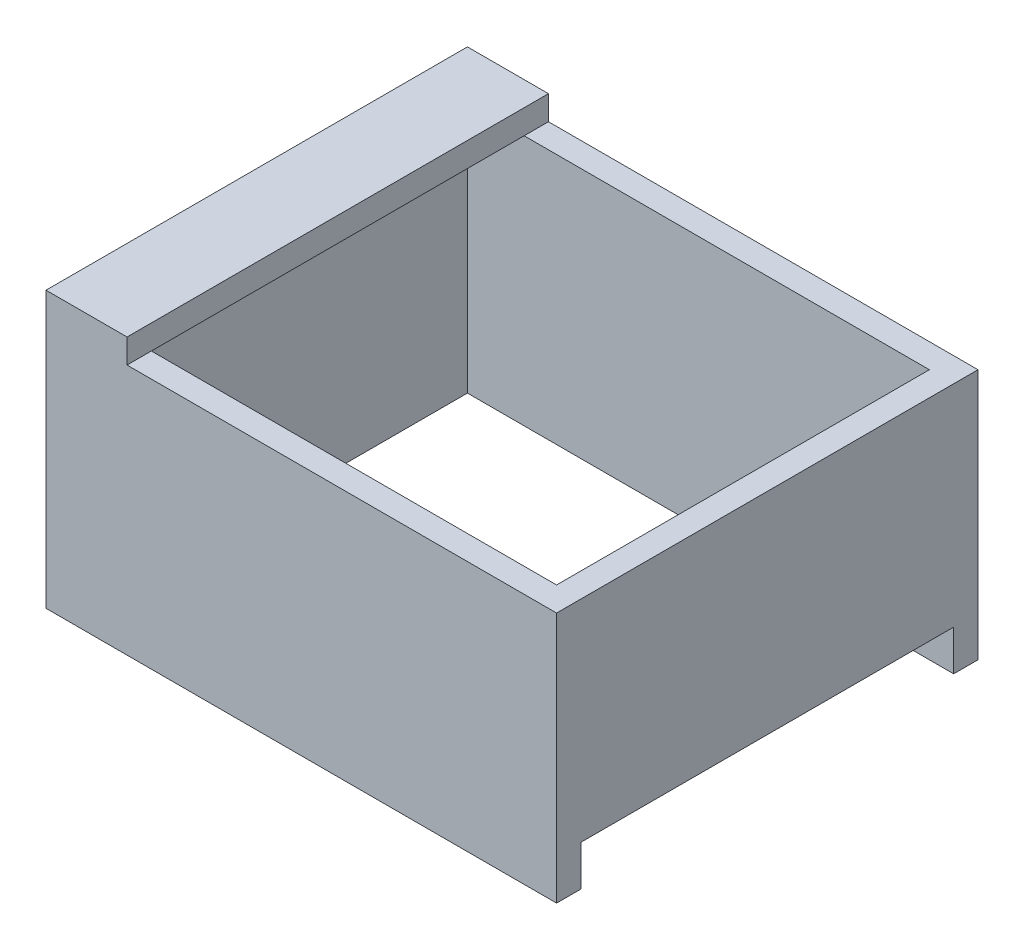
from build123d import *

# Parameters (mm, degrees)
SKETCH2_W           = 63
SKETCH2_H           = 52
BOSS_EXTRUDE1_DEPTH = 31
SKETCH1_W           = 57
SKETCH1_H           = 46
CUT_EXTRUDE1_DEPTH  = 31
SKETCH3_W           = 3
SKETCH3_H           = 46
CUT_EXTRUDE2_DEPTH  = 5
SKETCH4_W           = 52
SKETCH4_H           = 3
BOSS_EXTRUDE2_DEPTH = 17
SKETCH5_W           = 10
SKETCH5_H           = 52
BOSS_EXTRUDE3_DEPTH = 3


with BuildPart() as part:
    # Sketch2 → Boss-Extrude1 (new body)
    with BuildSketch(Plane(origin=(0, 0, 0), x_dir=(1, 0, 0), z_dir=(0, 1, 0))):
        with Locations((28.5, -23)):
            Rectangle(SKETCH2_W, SKETCH2_H)
    extrude(amount=BOSS_EXTRUDE1_DEPTH)

    # Sketch1 → Cut-Extrude1 (cut)
    with BuildSketch(Plane(origin=(0, 0, 0), x_dir=(1, 0, 0), z_dir=(0, 1, 0))):
        with Locations((28.5, -23)):
            Rectangle(SKETCH1_W, SKETCH1_H)
    extrude(amount=CUT_EXTRUDE1_DEPTH, mode=Mode.SUBTRACT)

    # Sketch3 → Cut-Extrude2 (cut)
    with BuildSketch(Plane.XZ):
        with Locations((58.5, 23)):
            Rectangle(SKETCH3_W, SKETCH3_H)
    extrude(amount=-CUT_EXTRUDE2_DEPTH, mode=Mode.SUBTRACT)

    # Sketch4 → Boss-Extrude2 (add)
    with BuildSketch(Plane(origin=(0, 0, 46), x_dir=(-1, 0, 0), z_dir=(0, 0, -1))):
        with Locations((-26, 9.5)):
            Rectangle(SKETCH4_W, SKETCH4_H)
    extrude(amount=BOSS_EXTRUDE2_DEPTH)

    # Sketch5 → Boss-Extrude3 (add)
    with BuildSketch(Plane(origin=(0, 31, 0), x_dir=(1, 0, 0), z_dir=(0, 1, 0))):
        with Locations((2, -23)):
            Rectangle(SKETCH5_W, SKETCH5_H)
    extrude(amount=BOSS_EXTRUDE3_DEPTH)


solid = part.part
